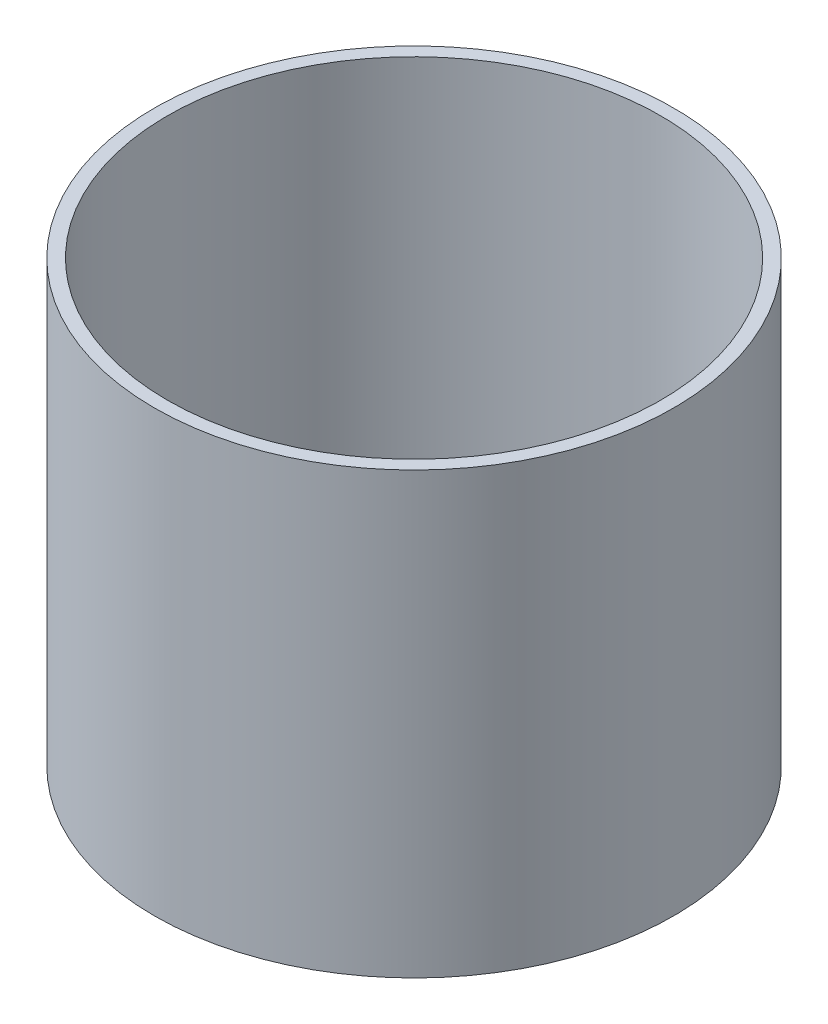
from build123d import *

# Parameters (mm, degrees)
SKETCH1_R           = 93.6625
SKETCH1_R_2         = 88.9
BOSS_EXTRUDE1_DEPTH = 79.32166


with BuildPart() as part:
    # Sketch1 → Boss-Extrude1 (new body, symmetric)
    with BuildSketch(Plane(origin=(0, 0, 0), x_dir=(1, 0, 0), z_dir=(0, 1, 0))):
        Circle(SKETCH1_R)
        Circle(SKETCH1_R_2, mode=Mode.SUBTRACT)
    extrude(amount=BOSS_EXTRUDE1_DEPTH, both=True)


solid = part.part
